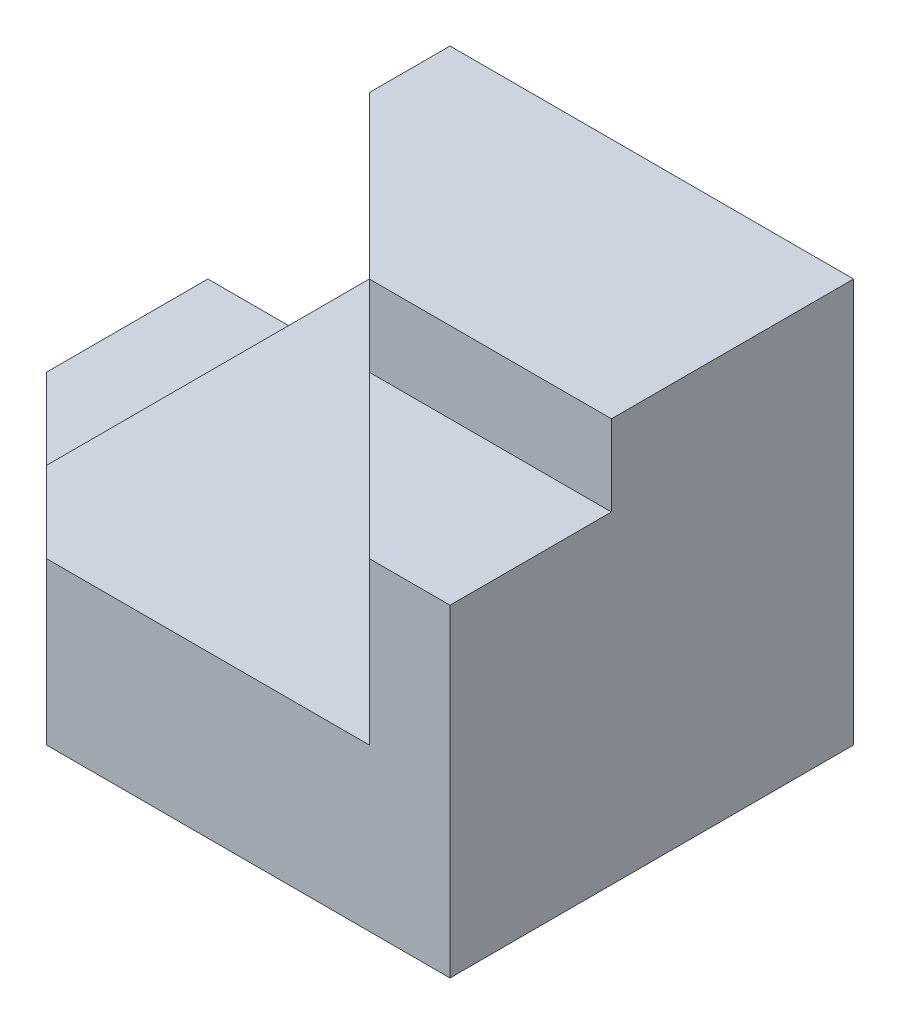
from build123d import *

# Parameters (mm, degrees)
SKETCH1_W           = 80
SKETCH1_H           = 50
BOSS_EXTRUDE1_DEPTH = 10
CUT_EXTRUDE1_DEPTH  = 10
BOSS_EXTRUDE2_DEPTH = 10
BOSS_EXTRUDE3_DEPTH = 20
BOSS_EXTRUDE4_DEPTH = 10


with BuildPart() as part:
    # Sketch1 → Boss-Extrude1 (new body)
    with BuildSketch(Plane(origin=(0, 0, 0), x_dir=(1, 0, 0), z_dir=(0, 1, 0))):
        with Locations((40, 25)):
            Rectangle(SKETCH1_W, SKETCH1_H)
    extrude(amount=BOSS_EXTRUDE1_DEPTH)

    # Sketch2 → Cut-Extrude1 (cut)
    with BuildSketch(Plane(origin=(0, 10, 0), x_dir=(1, 0, 0), z_dir=(0, 1, 0))):
        Polygon((0, 30), (30, 0), (0, 0), align=None)
    extrude(amount=-CUT_EXTRUDE1_DEPTH, mode=Mode.SUBTRACT)

    # Sketch3 → Boss-Extrude2 (add)
    with BuildSketch(Plane(origin=(0, 10, 0), x_dir=(1, 0, 0), z_dir=(0, 1, 0))):
        Polygon((80, 50), (80, 0), (30, 0), (20, 10), (20, 50), align=None)
    extrude(amount=BOSS_EXTRUDE2_DEPTH)

    # Sketch4 → Boss-Extrude3 (add)
    with BuildSketch(Plane(origin=(0, 20, 0), x_dir=(1, 0, 0), z_dir=(0, 1, 0))):
        Polygon((80, 50), (80, 0), (70, 0), (30, 40), (30, 50), align=None)
    extrude(amount=BOSS_EXTRUDE3_DEPTH)

    # Sketch5 → Boss-Extrude4 (add)
    with BuildSketch(Plane(origin=(0, 40, 0), x_dir=(1, 0, 0), z_dir=(0, 1, 0))):
        Polygon((80, 50), (80, 20), (50, 20), (30, 40), (30, 50), align=None)
    extrude(amount=BOSS_EXTRUDE4_DEPTH)


solid = part.part
